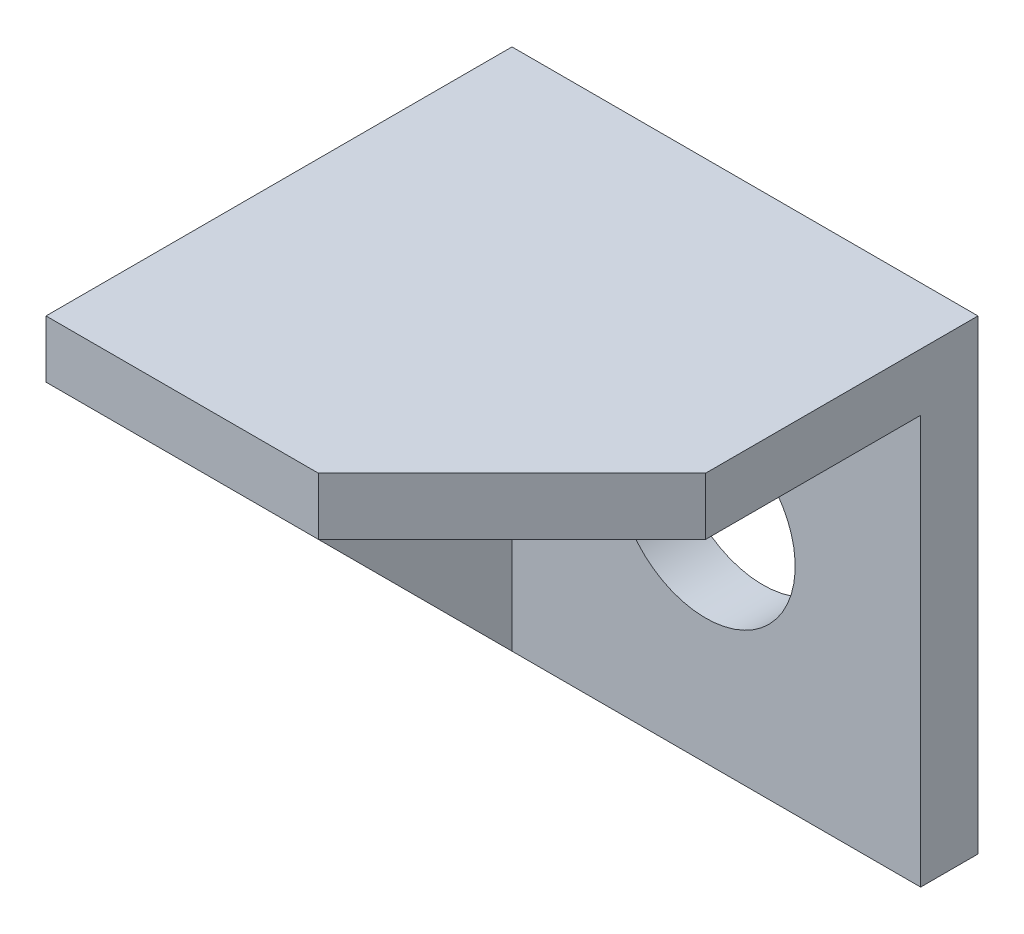
from build123d import *

# Parameters (mm, degrees)
SKETCH2_W           = 65
SKETCH2_H           = 65
BOSS_EXTRUDE1_DEPTH = 65
SKETCH3_W           = 57
SKETCH3_H           = 57
CUT_EXTRUDE1_DEPTH  = 57
CUT_EXTRUDE2_DEPTH  = 9
CUT_EXTRUDE3_DEPTH  = 9
SKETCH8_R           = 12.5
CUT_EXTRUDE4_DEPTH  = 66


with BuildPart() as part:
    # Sketch2 → Boss-Extrude1 (new body)
    with BuildSketch(Plane.XY):
        Rectangle(SKETCH2_W, SKETCH2_H)
    extrude(amount=BOSS_EXTRUDE1_DEPTH)

    # Sketch3 → Cut-Extrude1 (cut)
    with BuildSketch(Plane.XY.offset(65)):
        with Locations((4, -4)):
            Rectangle(SKETCH3_W, SKETCH3_H)
    extrude(amount=-CUT_EXTRUDE1_DEPTH, mode=Mode.SUBTRACT)

    # Sketch5 → Cut-Extrude2 (cut, through all)
    with BuildSketch(Plane(origin=(-24.5, 0, 0), x_dir=(0, 0, -1), z_dir=(1, 0, 0))):
        Polygon((-65, -32.5), (-65, 24.5), (-8, -32.5), align=None)
    extrude(amount=-CUT_EXTRUDE2_DEPTH, mode=Mode.SUBTRACT)

    # Sketch7 → Cut-Extrude3 (cut, through all)
    with BuildSketch(Plane(origin=(0, 24.5, 0), x_dir=(-1, 0, 0), z_dir=(0, -1, 0))):
        Polygon((-32.5, -65), (-5.5, -65), (-32.5, -38), align=None)
    extrude(amount=-CUT_EXTRUDE3_DEPTH, mode=Mode.SUBTRACT)

    # Sketch8 → Cut-Extrude4 (cut, through all)
    with BuildSketch(Plane(origin=(0, 0, 0), x_dir=(-1, 0, 0), z_dir=(0, 0, -1))):
        with Locations((-2.5, -2.5)):
            Circle(SKETCH8_R)
    extrude(amount=-CUT_EXTRUDE4_DEPTH, mode=Mode.SUBTRACT)


solid = part.part
